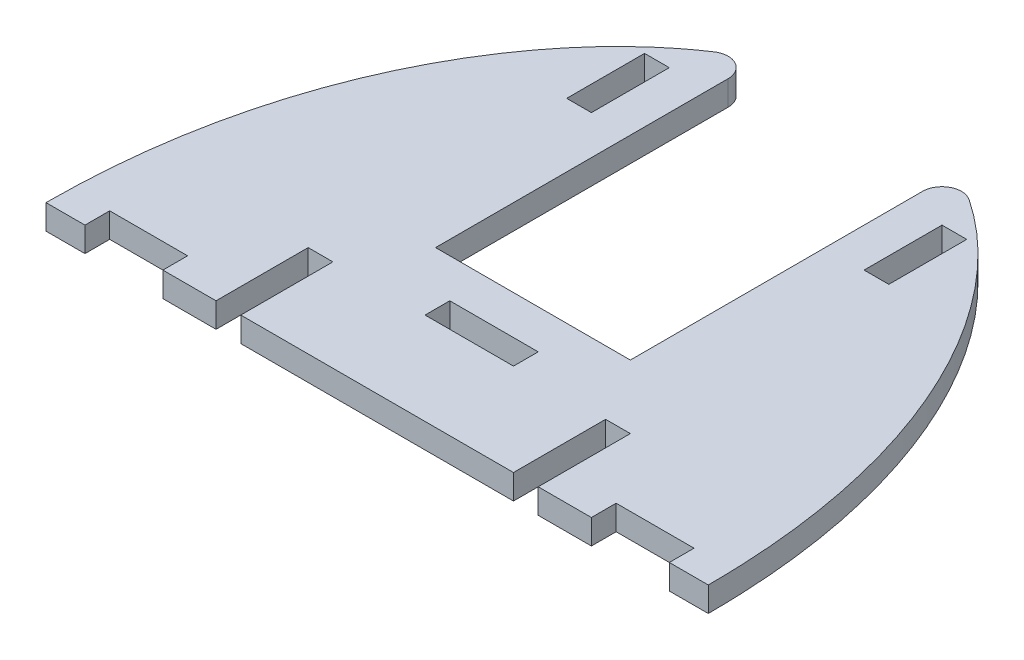
from build123d import *

# Parameters (mm, degrees)
BOSS_EXTRUDE1_DEPTH = 3.175
SKETCH3_W           = 3.175
SKETCH3_H           = 11.825
SKETCH3_W_2         = 11.35
SKETCH3_H_2         = 3.175
SKETCH3_W_3         = 25
SKETCH3_H_3         = 49.488701784
SKETCH3_H_4         = 10
SKETCH3_W_4         = 10
CUT_EXTRUDE2_DEPTH  = 4.1750001
FILLET1_R           = 2.5


with BuildPart() as part:
    # Sketch1 → Boss-Extrude1 (new body)
    with BuildSketch(Plane(origin=(0, 0, 0), x_dir=(1, 0, 0), z_dir=(0, 1, 0))):
        with BuildLine():
            add(Edge.make_bspline(
                [(0, 0), (0, 36), (20.385499073, 62.552567554), (40.487505944, 65), (42.5, 65)],
                knots=[0, 0, 0, 0, 0.452811163, 0.503123514, 0.503123514, 0.503123514, 0.503123514], degree=3))
            Line((0, 0), (42.5, 0))
            Line((42.5, 0), (42.5, 65))
        make_face()
        with BuildLine():
            Line((42.5, 65), (42.5, 0))
            Line((42.5, 0), (85, 0))
            add(Edge.make_bspline(
                [(42.5, 65), (44.487505944, 65), (64.384933097, 62.612967274), (85, 36), (85, 0)],
                knots=[0.503123514, 0.503123514, 0.503123514, 0.503123514, 0.552811163, 1, 1, 1, 1], degree=3))
        make_face()
    extrude(amount=BOSS_EXTRUDE1_DEPTH)

    # Sketch3 → Cut-Extrude2 (cut, through all)
    with BuildSketch(Plane(origin=(0, 3.175, 0), x_dir=(1, 0, 0), z_dir=(0, 1, 0))):
        with Locations((23.4125, 5.9125)):
            Rectangle(SKETCH3_W, SKETCH3_H)
        with Locations((61.5875, 5.9125)):
            Rectangle(SKETCH3_W, SKETCH3_H)
        with Locations((42.5, 13.4125)):
            Rectangle(SKETCH3_W_2, SKETCH3_H_2)
        with Locations((42.5, 44.744350892)):
            Rectangle(SKETCH3_W_3, SKETCH3_H_3)
        with Locations((23.4125, 50)):
            Rectangle(SKETCH3_W, SKETCH3_H_4)
        with Locations((61.5875, 50)):
            Rectangle(SKETCH3_W, SKETCH3_H_4)
        with Locations((10, 1.5875)):
            Rectangle(SKETCH3_W_4, SKETCH3_H_2)
        with Locations((75, 1.5875)):
            Rectangle(SKETCH3_W_4, SKETCH3_H_2)
    extrude(amount=-CUT_EXTRUDE2_DEPTH, mode=Mode.SUBTRACT)

    # Fillet1
    fillet1_edges = [part.edges().sort_by_distance(p)[0] for p in [
        (30, 1.5875, -61.882691036),
        (55, 1.5875, -61.855383827),
    ]]
    fillet(fillet1_edges, radius=FILLET1_R)


solid = part.part
